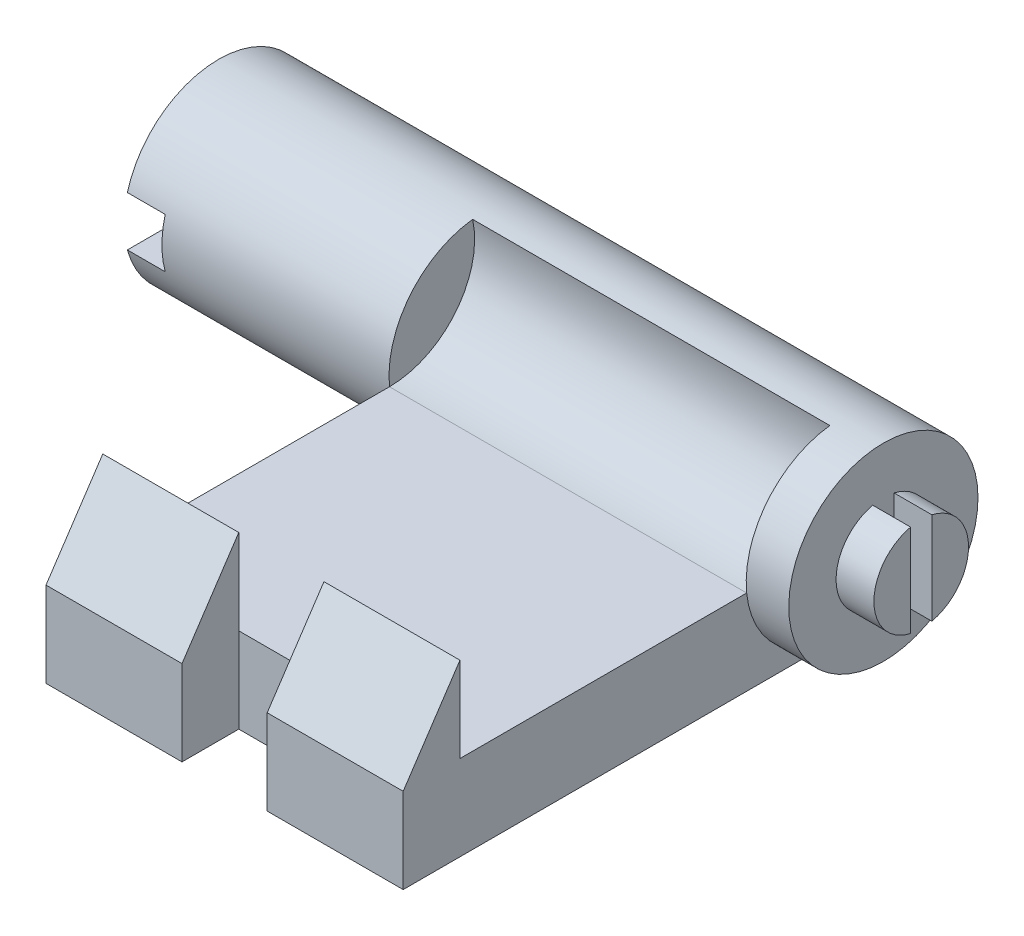
from build123d import *

# Parameters (mm, degrees)
SKETCH2_W               = 81.788
SKETCH2_H               = 18.288
BOSS_EXTRUDE1_DEPTH     = 38.354
SKETCH3_R               = 20.32
BOSS_EXTRUDE2_DEPTH     = 9.144
BOSS_EXTRUDE3_START     = 9.144
BOSS_EXTRUDE3_DEPTH     = 8.128
BOSS_EXTRUDE4_START     = -76.708
SKETCH3_4_R             = 20.32
BOSS_EXTRUDE4_DEPTH     = 56.896
CUT_EXTRUDE1_DEPTH      = 8.128
SKETCH5_W               = 18.288
SKETCH5_H               = 12.192
CUT_EXTRUDE3_DEPTH      = 23.352
CUT_EXTRUDE3_DEPTH_BACK = 19.288


with BuildPart() as part:
    # Sketch2 → Boss-Extrude1 (new body, symmetric)
    with BuildSketch(Plane(origin=(0, 0, 0), x_dir=(0, 0, -1), z_dir=(1, 0, 0))):
        with Locations((-40.894, 9.144)):
            Rectangle(SKETCH2_W, SKETCH2_H)
        Polygon((-81.788, 36.576), (-81.788, 18.288), (-81.788, 0), (-93.98, 0), (-93.98, 18.288), align=None)
        with BuildLine():
            Line((0, 18.288), (0, 0))
            ThreePointArc((0, 0), (20.285688823, 21.500351201), (-2.356716256, 40.502871166))
            ThreePointArc((-2.356716256, 40.502871166), (-2.037100365, 38.550986103), (-1.930144722, 36.576))
            ThreePointArc((-1.930144722, 36.576), (-7.286575908, 23.644431186), (-20.218144722, 18.288))
            Line((-20.218144722, 18.288), (0, 18.288))
        make_face()
    extrude(amount=BOSS_EXTRUDE1_DEPTH, both=True)

    # Sketch3 → Boss-Extrude2 (add)
    with BuildSketch(Plane(origin=(38.354, 0, 0), x_dir=(0, 0, -1), z_dir=(1, 0, 0))):
        with Locations((0, 20.32)):
            Circle(SKETCH3_R)
    extrude(amount=BOSS_EXTRUDE2_DEPTH)

    # Sketch3_3 → Boss-Extrude3 (add)
    with BuildSketch(Plane(origin=(38.354, 0, 0), x_dir=(0, 0, -1), z_dir=(1, 0, 0)).offset(BOSS_EXTRUDE3_START)):
        with BuildLine():
            Line((-2.286, 10.420514963), (-2.286, 30.219485037))
            ThreePointArc((-2.286, 30.219485037), (-2.727219055, 30.107128089), (-3.162961291, 29.975116564))
            ThreePointArc((-3.162961291, 29.975116564), (-5.965678902, 25.116586312), (-10.109072361, 21.336))
            ThreePointArc((-10.109072361, 21.336), (-8.258111655, 14.401453566), (-2.286, 10.420514963))
        make_face()
        with BuildLine():
            ThreePointArc((10.16, 20.32), (7.951457728, 26.644548996), (2.286, 30.219485037))
            Line((2.286, 30.219485037), (2.286, 10.420514963))
            ThreePointArc((2.286, 10.420514963), (7.951457728, 13.995451004), (10.16, 20.32))
        make_face()
        with BuildLine():
            ThreePointArc((-10.109072361, 21.336), (-5.965678902, 25.116586312), (-3.162961291, 29.975116564))
            ThreePointArc((-3.162961291, 29.975116564), (-7.918036566, 26.686340938), (-10.109072361, 21.336))
        make_face()
    extrude(amount=BOSS_EXTRUDE3_DEPTH)

    # Sketch3_4 → Boss-Extrude4 (add)
    with BuildSketch(Plane(origin=(38.354, 0, 0), x_dir=(0, 0, -1), z_dir=(1, 0, 0)).offset(BOSS_EXTRUDE4_START)):
        with Locations((0, 20.32)):
            Circle(SKETCH3_4_R)
    extrude(amount=-BOSS_EXTRUDE4_DEPTH)

    # Sketch4 → Cut-Extrude1 (cut)
    with BuildSketch(Plane.ZY.offset(95.25)):
        with BuildLine():
            Line((19.607418086, 25.654), (-19.607418086, 25.654))
            ThreePointArc((-19.607418086, 25.654), (-20.32, 20.32), (-19.607418086, 14.986))
            Line((-19.607418086, 14.986), (19.607418086, 14.986))
            ThreePointArc((19.607418086, 14.986), (20.141066699, 17.629306363), (20.32, 20.32))
            ThreePointArc((20.32, 20.32), (20.141066699, 23.010693637), (19.607418086, 25.654))
        make_face()
    extrude(amount=-CUT_EXTRUDE1_DEPTH, mode=Mode.SUBTRACT)

    # Sketch5 → Cut-Extrude3 (cut, two sides)
    with BuildSketch(Plane(origin=(0, 18.288, 0), x_dir=(1, 0, 0), z_dir=(0, 1, 0))) as cut_extrude3_sk:
        with Locations((0, -87.884)):
            Rectangle(SKETCH5_W, SKETCH5_H)
    extrude(amount=CUT_EXTRUDE3_DEPTH, mode=Mode.SUBTRACT)
    extrude(cut_extrude3_sk.sketch, amount=-CUT_EXTRUDE3_DEPTH_BACK, mode=Mode.SUBTRACT)


solid = part.part
